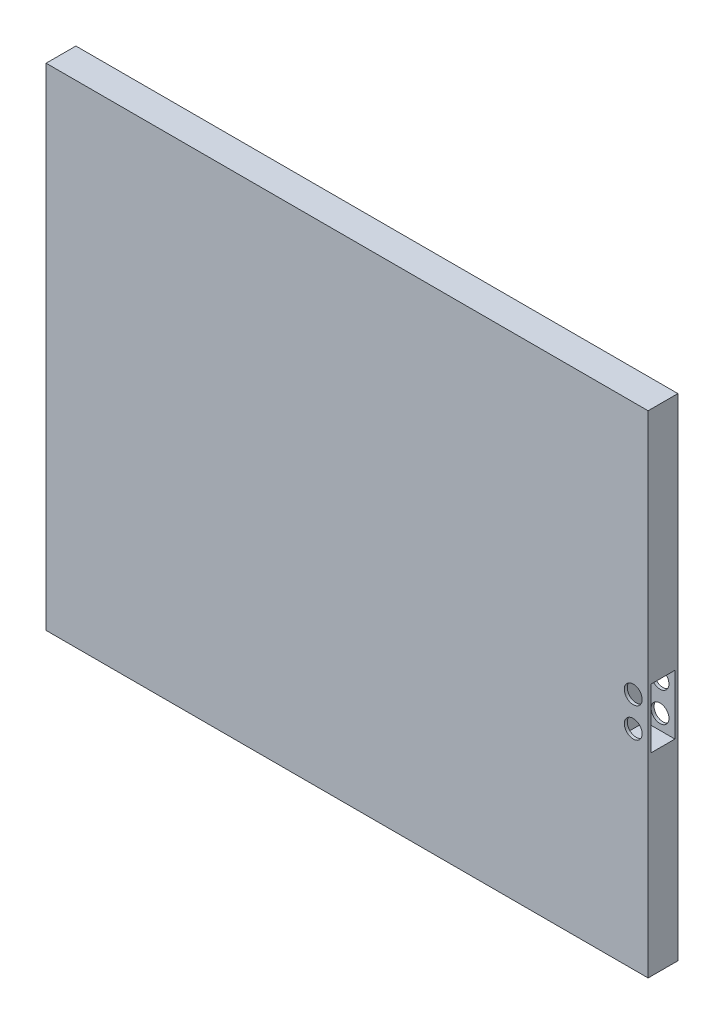
from build123d import *

# Parameters (mm, degrees)
SKETCH1_W           = 256.794
SKETCH1_H           = 196.85
BOSS_EXTRUDE1_DEPTH = 12.7
SKETCH2_W           = 10.16
SKETCH2_H           = 25.4
CUT_EXTRUDE1_DEPTH  = 12.7
SKETCH3_R           = 3.81
CUT_EXTRUDE2_DEPTH  = 12.7
SKETCH4_W           = 256.794
SKETCH4_H           = 12.7
BOSS_EXTRUDE2_DEPTH = 12.7


with BuildPart() as part:
    # Sketch1 → Boss-Extrude1 (new body)
    with BuildSketch(Plane.XY):
        with Locations((50.169769953, -9.226877934)):
            Rectangle(SKETCH1_W, SKETCH1_H)
    extrude(amount=BOSS_EXTRUDE1_DEPTH)

    # Sketch2 → Cut-Extrude1 (cut)
    with BuildSketch(Plane(origin=(178.566769953, 0, 0), x_dir=(0, 0, -1), z_dir=(1, 0, 0))):
        with Locations((-6.35, -12.393940124)):
            Rectangle(SKETCH2_W, SKETCH2_H)
    extrude(amount=-CUT_EXTRUDE1_DEPTH, mode=Mode.SUBTRACT)

    # Sketch3 → Cut-Extrude2 (cut)
    with BuildSketch(Plane.XY.offset(12.7)):
        with Locations((172.216769953, -6.043940124)):
            Circle(SKETCH3_R)
        with Locations((172.216769953, -18.743940124)):
            Circle(SKETCH3_R)
    extrude(amount=-CUT_EXTRUDE2_DEPTH, mode=Mode.SUBTRACT)

    # Sketch4 → Boss-Extrude2 (add)
    with BuildSketch(Plane(origin=(0, 89.198122066, 0), x_dir=(1, 0, 0), z_dir=(0, 1, 0))):
        with Locations((50.169769953, -6.35)):
            Rectangle(SKETCH4_W, SKETCH4_H)
    extrude(amount=BOSS_EXTRUDE2_DEPTH)


solid = part.part
